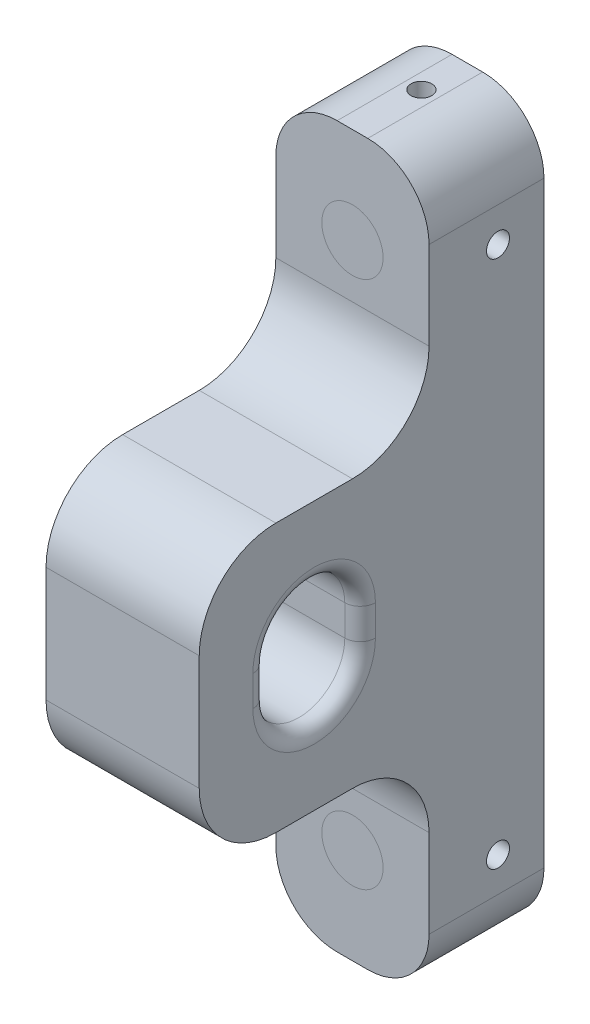
from build123d import *

# Parameters (mm, degrees)
SKETCH1_W             = 20
SKETCH1_H             = 93.98
BOSS_EXTRUDE1_DEPTH   = 15
FILLET1_R             = 8
SKETCH2_R             = 4
CUT_EXTRUDE1_DEPTH    = 16
SKETCH3_R             = 1.5
CUT_EXTRUDE2_DEPTH    = 21
SKETCH4_W             = 30
SKETCH4_H             = 35
BOSS_EXTRUDE2_DEPTH   = 20
FILLET2_R             = 10
CUT_EXTRUDE3_DEPTH    = 21.0000001
FILLET3_R             = 2
SKETCH6_R             = 1.35
CUT_EXTRUDE4_DEPTH    = 10
SKETCH7_R             = 4
BOSS_EXTRUDE3_DEPTH   = 2
BOSS_EXTRUDE3_2_DEPTH = 2


with BuildPart() as part:
    # Sketch1 → Boss-Extrude1 (new body)
    with BuildSketch(Plane.XY):
        Rectangle(SKETCH1_W, SKETCH1_H)
    extrude(amount=BOSS_EXTRUDE1_DEPTH)

    # Fillet1
    fillet1_edges = [part.edges().sort_by_distance(p)[0] for p in [
        (10, -46.99, 7.5),
        (-10, -46.99, 7.5),
        (-10, 46.99, 7.5),
        (10, 46.99, 7.5),
    ]]
    fillet(fillet1_edges, radius=FILLET1_R)

    # Sketch2 → Cut-Extrude1 (cut, through all)
    with BuildSketch(Plane.XY.offset(15)):
        with Locations((0, 34.49)):
            Circle(SKETCH2_R)
        with Locations((0, -34.494880812)):
            Circle(SKETCH2_R)
    extrude(amount=-CUT_EXTRUDE1_DEPTH, mode=Mode.SUBTRACT)

    # Sketch3 → Cut-Extrude2 (cut, through all)
    with BuildSketch(Plane.ZY.offset(10)):
        with Locations((6, 34.49)):
            Circle(SKETCH3_R)
        with Locations((6, -34.494880812)):
            Circle(SKETCH3_R)
    extrude(amount=-CUT_EXTRUDE2_DEPTH, mode=Mode.SUBTRACT)

    # Sketch4 → Boss-Extrude2 (add)
    with BuildSketch(Plane.ZY.offset(10)):
        with Locations((30, 0)):
            Rectangle(SKETCH4_W, SKETCH4_H)
    extrude(amount=-BOSS_EXTRUDE2_DEPTH)

    # Fillet2
    fillet2_edges = [part.edges().sort_by_distance(p)[0] for p in [
        (0, -17.5, 15),
        (0, 17.5, 15),
        (0, 17.5, 45),
        (0, -17.5, 45),
    ]]
    fillet(fillet2_edges, radius=FILLET2_R)

    # Sketch5 → Cut-Extrude3 (cut, through all)
    with BuildSketch(Plane(origin=(10, 0, 0), x_dir=(0, 0, -1), z_dir=(1, 0, 0))):
        with BuildLine():
            Line((-24, 2), (-24, -2))
            ThreePointArc((-24, -2), (-30, -8), (-36, -2))
            Line((-36, -2), (-36, 2))
            ThreePointArc((-36, 2), (-30, 8), (-24, 2))
        make_face()
    extrude(amount=-CUT_EXTRUDE3_DEPTH, mode=Mode.SUBTRACT)

    # Fillet3
    fillet3_edges = [part.edges().sort_by_distance(p)[0] for p in [
        (-10, 8, 30),
        (-10, 0, 24),
        (-10, -8, 30),
        (-10, 0, 36),
        (10, 8, 30),
        (10, 0, 36),
        (10, -8, 30),
        (10, 0, 24),
    ]]
    fillet(fillet3_edges, radius=FILLET3_R)

    # Sketch6 → Cut-Extrude4 (cut)
    with BuildSketch(Plane(origin=(0, 46.99, 0), x_dir=(1, 0, 0), z_dir=(0, 1, 0))):
        with Locations((0, -6)):
            Circle(SKETCH6_R)
    cut_extrude4 = extrude(amount=-CUT_EXTRUDE4_DEPTH, mode=Mode.SUBTRACT)

    # Mirror1: Cut-Extrude4 across plane
    add(cut_extrude4.mirror(Plane.ZX), mode=Mode.SUBTRACT)


with BuildPart() as body_2:
    # Sketch7 → Boss-Extrude3 (new body)
    with BuildSketch(Plane.XY.offset(15)):
        with Locations((0, 34.49)):
            Circle(SKETCH7_R)
    extrude(amount=-BOSS_EXTRUDE3_DEPTH)


with BuildPart() as body_3:
    # Sketch7 → Boss-Extrude3 2 (new body)
    with BuildSketch(Plane.XY.offset(15)):
        with Locations((0, -34.494880812)):
            Circle(SKETCH7_R)
    extrude(amount=-BOSS_EXTRUDE3_2_DEPTH)


solid = Compound([part.part, body_2.part, body_3.part])
